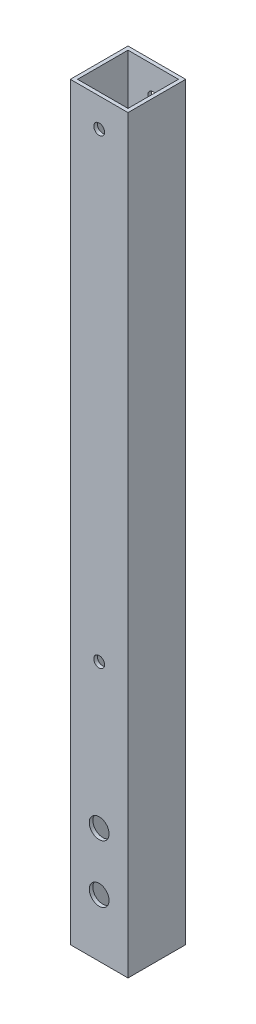
from build123d import *

# Parameters (mm, degrees)
SKETCH1_W           = 25.4
SKETCH1_H           = 25.4
SKETCH1_W_2         = 22.225
SKETCH1_H_2         = 22.225
BOSS_EXTRUDE1_DEPTH = 330.2
SKETCH2_R           = 4.365625
SKETCH2_R_2         = 2.38125
CUT_EXTRUDE1_DEPTH  = 25.4


with BuildPart() as part:
    # Sketch1 → Boss-Extrude1 (new body)
    with BuildSketch(Plane(origin=(0, 0, 0), x_dir=(1, 0, 0), z_dir=(0, 1, 0))):
        Rectangle(SKETCH1_W, SKETCH1_H)
        Rectangle(SKETCH1_W_2, SKETCH1_H_2, mode=Mode.SUBTRACT)
    extrude(amount=BOSS_EXTRUDE1_DEPTH)

    # Sketch2 → Cut-Extrude1 (cut)
    with BuildSketch(Plane.XY.offset(12.7)):
        with Locations((0, 25.4)):
            Circle(SKETCH2_R)
        with Locations((0, 50.8)):
            Circle(SKETCH2_R)
        with Locations((0, 317.5)):
            Circle(SKETCH2_R_2)
        with Locations((0, 114.3)):
            Circle(SKETCH2_R_2)
    extrude(amount=-CUT_EXTRUDE1_DEPTH, mode=Mode.SUBTRACT)


solid = part.part
